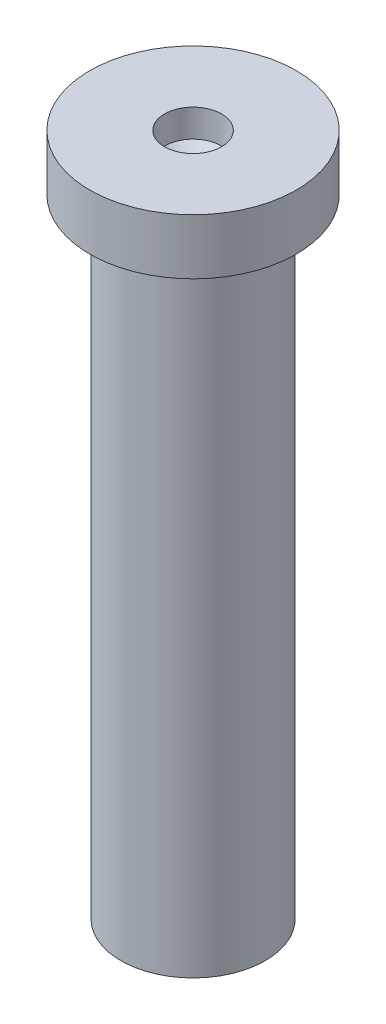
from build123d import *


with BuildPart() as part:
    # Sketch1 → Revolve1 (revolve)
    with BuildSketch(Plane.XY):
        Polygon((0, 0), (1.3, 0), (1.3, 11.3), (1.861447904, 11.3), (1.861447904, 12.3), (0.51316807, 12.3), (0.51316807, 11.8), (0, 11.440205857), align=None)
    revolve(axis=Axis((0, 0, 0), (0, 1, 0)))


solid = part.part
